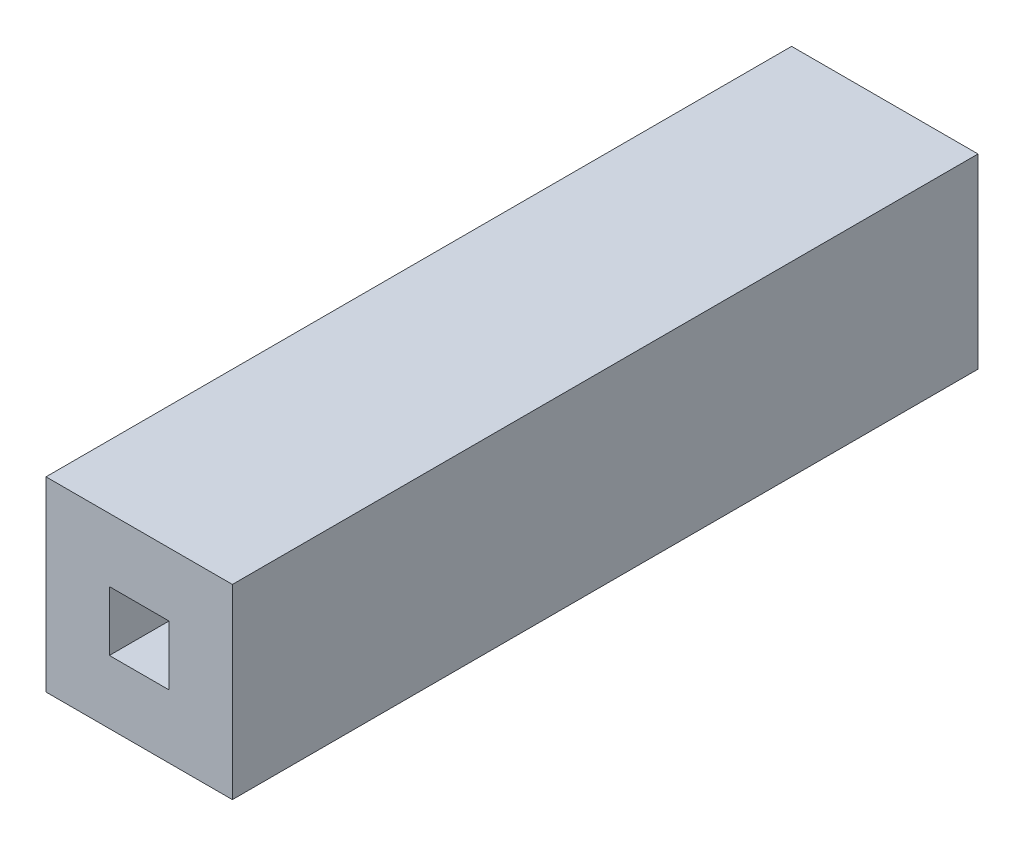
from build123d import *

# Parameters (mm, degrees)
SKETCH2_W           = 12.7
SKETCH2_H           = 12.7
BOSS_EXTRUDE1_DEPTH = 50.8
SKETCH4_W           = 4.064
SKETCH4_H           = 4.064
CUT_EXTRUDE1_DEPTH  = 51.8


with BuildPart() as part:
    # Sketch2 → Boss-Extrude1 (new body)
    with BuildSketch(Plane.XY):
        Rectangle(SKETCH2_W, SKETCH2_H)
    extrude(amount=BOSS_EXTRUDE1_DEPTH)

    # Sketch4 → Cut-Extrude1 (cut, through all)
    with BuildSketch(Plane(origin=(0, 0, 0), x_dir=(-1, 0, 0), z_dir=(0, 0, -1))):
        Rectangle(SKETCH4_W, SKETCH4_H)
    extrude(amount=-CUT_EXTRUDE1_DEPTH, mode=Mode.SUBTRACT)


solid = part.part
